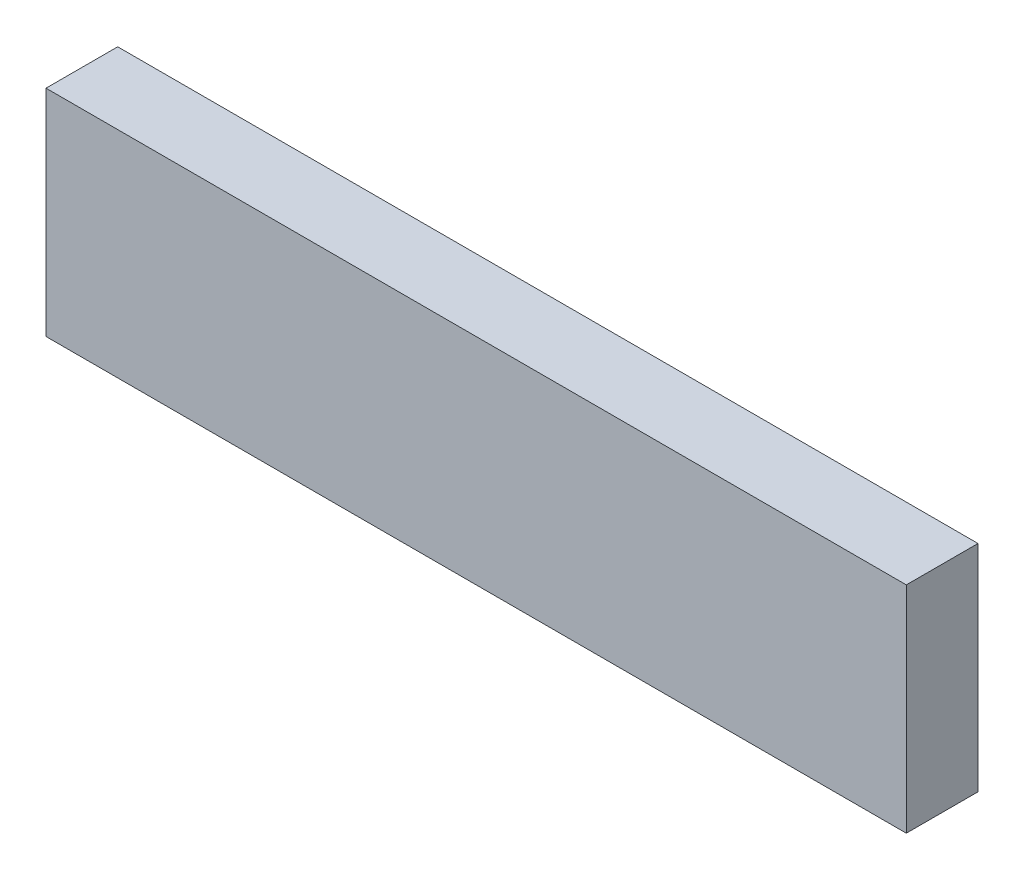
from build123d import *

# Parameters (mm, degrees)
SKETCH1_W           = 60
SKETCH1_H           = 15
BOSS_EXTRUDE1_DEPTH = 5


with BuildPart() as part:
    # Sketch1 → Boss-Extrude1 (new body)
    with BuildSketch(Plane.XY):
        with Locations((30, 7.5)):
            Rectangle(SKETCH1_W, SKETCH1_H)
    extrude(amount=BOSS_EXTRUDE1_DEPTH)


solid = part.part
